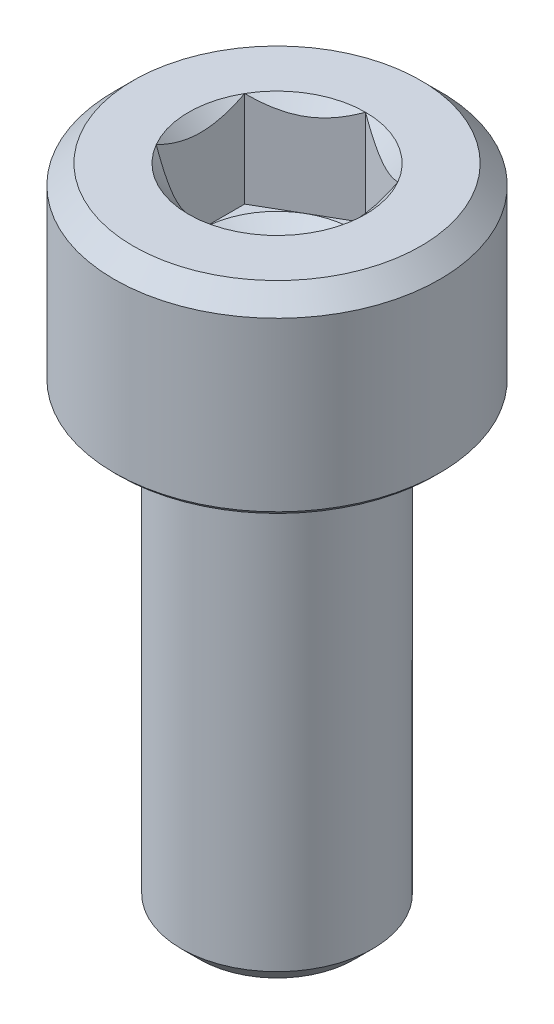
from build123d import *

# Parameters (mm, degrees)
CUT_EXTRUDE1_DEPTH = 2.5


with BuildPart() as part:
    # Sketch1 → Revolve1 (revolve)
    with BuildSketch(Plane.XY):
        Polygon((0, 1.345299462), (2, 2.5), (2, 4.690598923), (2.309401077, 5), (3.75, 5), (4.25, 4.5), (4.25, 0.125), (4.125, 0), (2.55, 0), (2.5, -0.6), (2.5, -11.5095), (2.0095, -12), (0, -12), align=None)
    revolve(axis=Axis((0, -12, 0), (0, 1, 0)))

    # Sketch2 → Cut-Extrude1 (cut)
    with BuildSketch(Plane(origin=(0, 5, 0), x_dir=(1, 0, 0), z_dir=(0, 1, 0))):
        Polygon((-2, -1.154700538), (0, -2.309401077), (2, -1.154700538), (2, 1.154700538), (0, 2.309401077), (-2, 1.154700538), align=None)
    extrude(amount=-CUT_EXTRUDE1_DEPTH, mode=Mode.SUBTRACT)


solid = part.part
